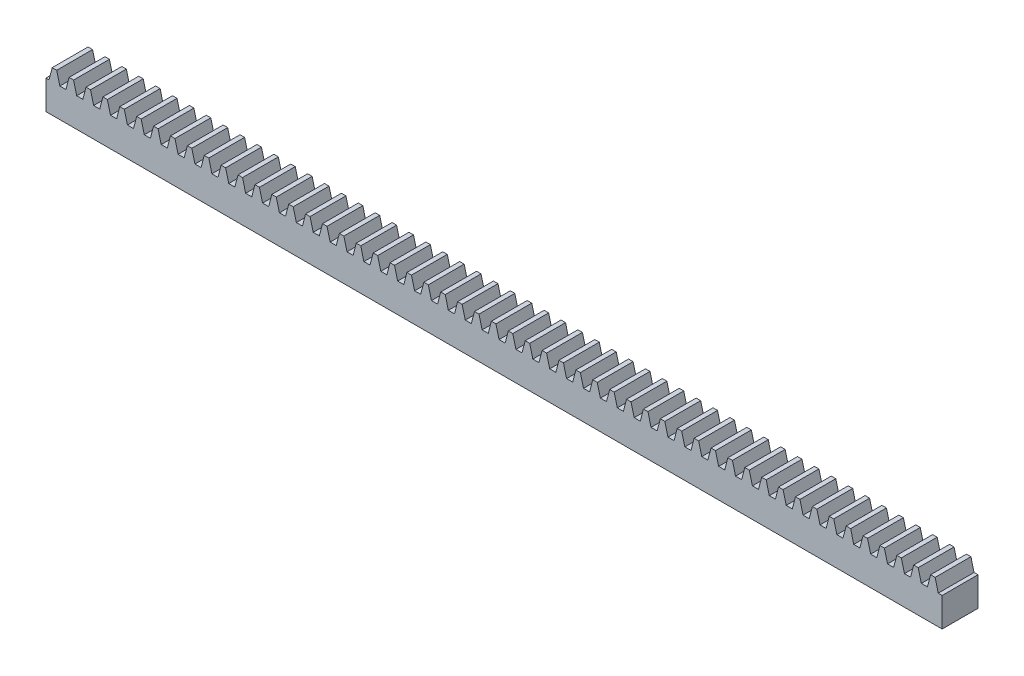
from build123d import *

# Parameters (mm, degrees)
BLANKSKE_W        = 250
BLANKSKE_H        = 11.5
BLANK_DEPTH       = 10
TOOTHCUTSIM_DEPTH = 251.464069279
TEETHCUTS_COUNT   = 54
TEETHCUTS_PITCH   = 4.712388975


with BuildPart() as part:
    # BlankSke → Blank (new body)
    with BuildSketch(Plane.XY):
        with Locations((125, 5.75)):
            Rectangle(BLANKSKE_W, BLANKSKE_H)
    extrude(amount=-BLANK_DEPTH)

    # TooCutSkeSim → ToothCutSim (cut, through all)
    with BuildSketch(Plane.XY):
        Polygon((0.852189273, 8.125), (-0.852189273, 8.125), (-1.731592507, 11.5254), (1.731592507, 11.5254), align=None)
    toothcutsim = extrude(amount=-TOOTHCUTSIM_DEPTH, mode=Mode.SUBTRACT)

    # TeethCuts: ToothCutSim ×54
    with Locations(*[(i * TEETHCUTS_PITCH, 0, 0) for i in range(1, TEETHCUTS_COUNT)]):
        add(toothcutsim, mode=Mode.SUBTRACT)


solid = part.part
